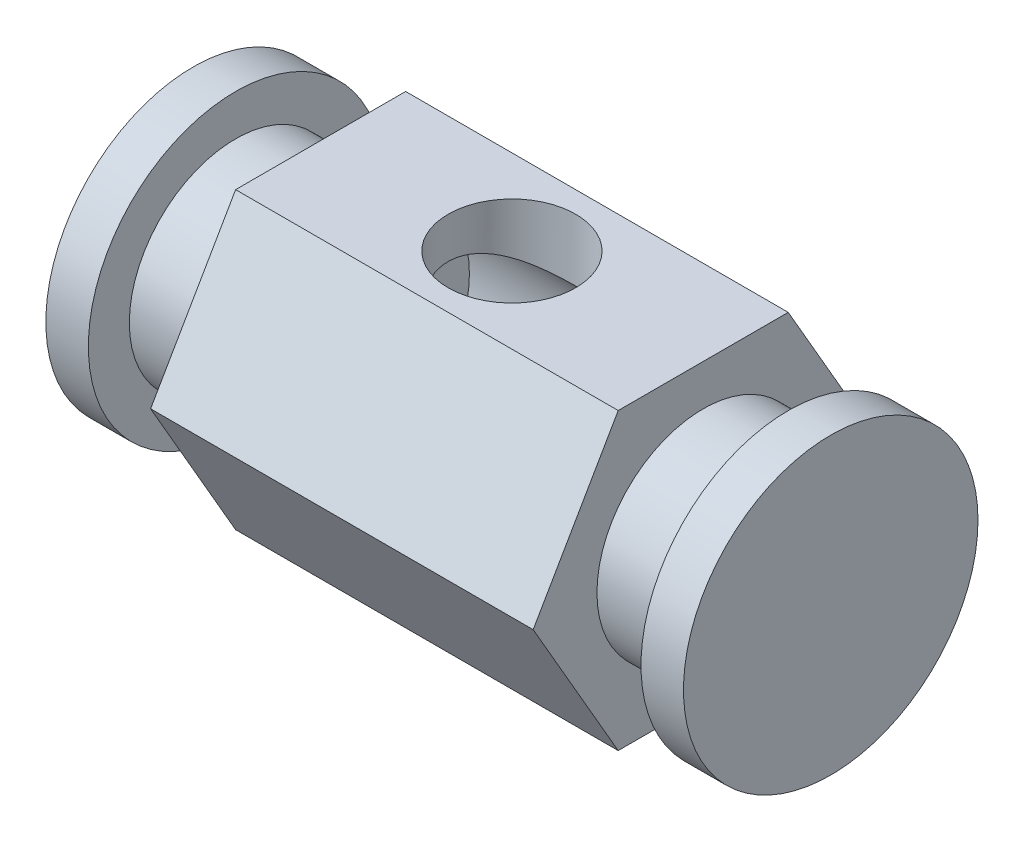
from build123d import *

# Parameters (mm, degrees)
SKETCH1_R               = 12.5
BOSS_EXTRUDE1_DEPTH     = 22.5
SKETCH2_R               = 7.5
CUT_EXTRUDE2_DEPTH      = 18.320508076
CUT_EXTRUDE2_DEPTH_BACK = 18.320508076
BOSS_EXTRUDE2_START     = -5
SKETCH3_R               = 12.5
BOSS_EXTRUDE2_DEPTH     = 15
SKETCH4_R               = 17.320508076
BOSS_EXTRUDE3_DEPTH     = 5


with BuildPart() as part:
    # Sketch1 → Boss-Extrude1 (new body, symmetric)
    with BuildSketch(Plane(origin=(0, 0, 0), x_dir=(0, 0, -1), z_dir=(1, 0, 0))):
        Polygon((10, 17.320508076), (-10, 17.320508076), (-20, 0), (-10, -17.320508076), (10, -17.320508076), (20, 0), align=None)
        Circle(SKETCH1_R, mode=Mode.SUBTRACT)
    extrude(amount=BOSS_EXTRUDE1_DEPTH, both=True)

    # Sketch2 → Cut-Extrude2 (cut, two sides)
    with BuildSketch(Plane(origin=(0, 0, 0), x_dir=(1, 0, 0), z_dir=(0, 1, 0))) as cut_extrude2_sk:
        Circle(SKETCH2_R)
    extrude(amount=CUT_EXTRUDE2_DEPTH, mode=Mode.SUBTRACT)
    extrude(cut_extrude2_sk.sketch, amount=-CUT_EXTRUDE2_DEPTH_BACK, mode=Mode.SUBTRACT)

    # Sketch3 → Boss-Extrude2 (add)
    with BuildSketch(Plane(origin=(22.5, 0, 0), x_dir=(0, 0, -1), z_dir=(1, 0, 0)).offset(BOSS_EXTRUDE2_START)):
        Circle(SKETCH3_R)
    boss_extrude2 = extrude(amount=BOSS_EXTRUDE2_DEPTH)

    # Sketch4 → Boss-Extrude3 (add)
    with BuildSketch(Plane(origin=(32.5, 0, 0), x_dir=(0, 0, -1), z_dir=(1, 0, 0))):
        Circle(SKETCH4_R)
    boss_extrude3 = extrude(amount=BOSS_EXTRUDE3_DEPTH)

    # Mirror3: Boss-Extrude2, Boss-Extrude3 across plane
    add(boss_extrude2.mirror(Plane(origin=(0, 0, 0), x_dir=(0, 0, 1), z_dir=(1, 0, 0))))
    add(boss_extrude3.mirror(Plane(origin=(0, 0, 0), x_dir=(0, 0, 1), z_dir=(1, 0, 0))))


solid = part.part
